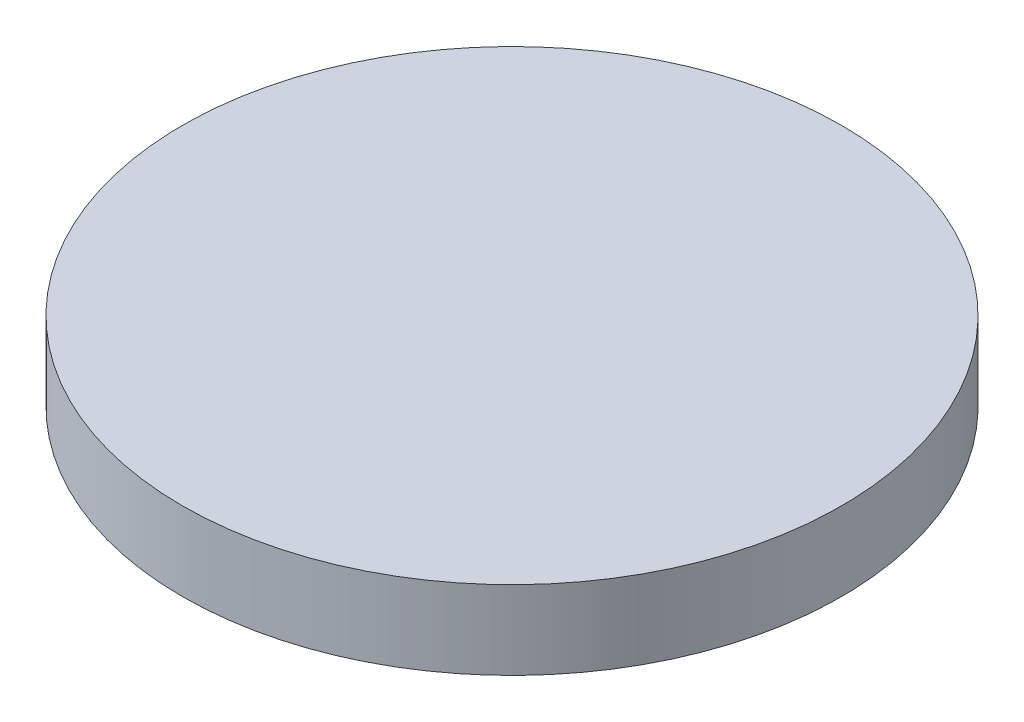
from build123d import *

# Parameters (mm, degrees)
SKETCH1_R           = 2.096
BOSS_EXTRUDE1_DEPTH = 0.5


with BuildPart() as part:
    # Sketch1 → Boss-Extrude1 (new body)
    with BuildSketch(Plane(origin=(0, 0, 0), x_dir=(1, 0, 0), z_dir=(0, 1, 0))):
        Circle(SKETCH1_R)
    extrude(amount=BOSS_EXTRUDE1_DEPTH)


solid = part.part
